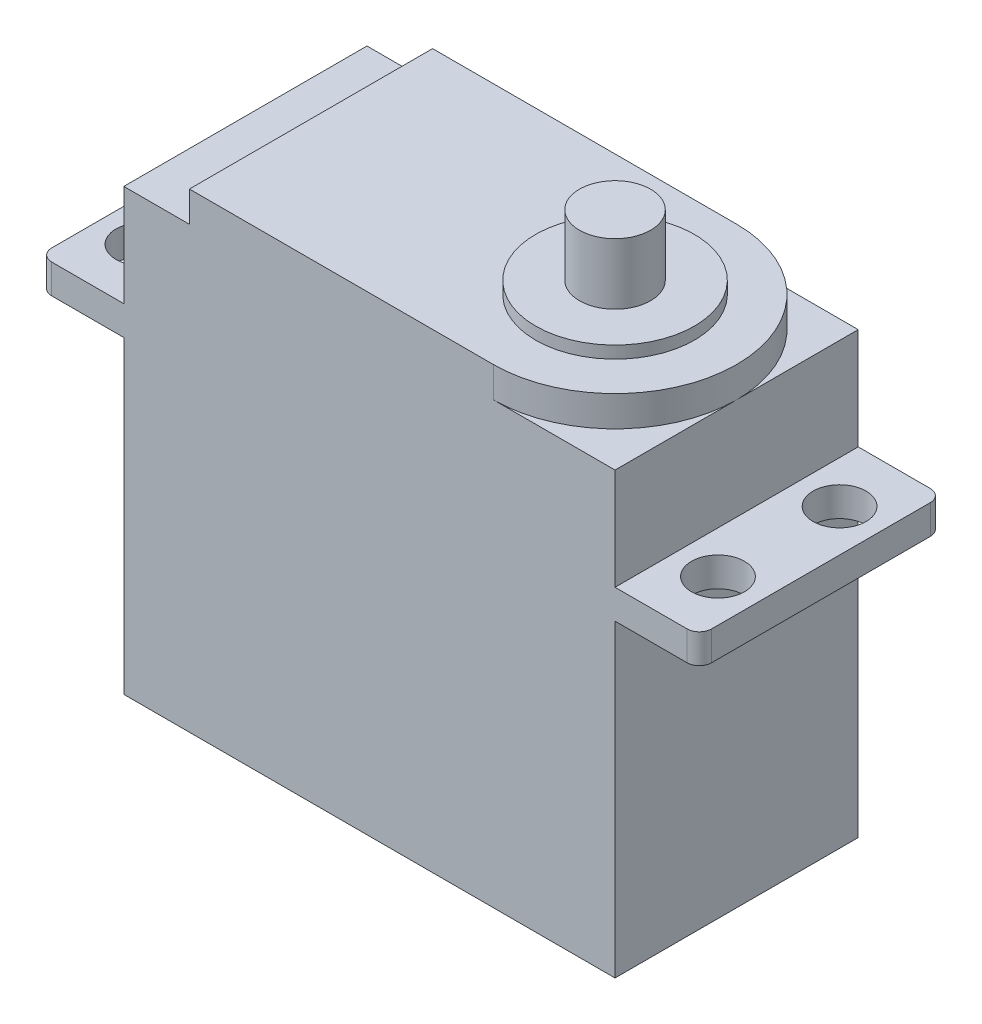
from build123d import *

# Parameters (mm, degrees)
CROQUIS1_W              = 40.2
CROQUIS1_H              = 19.9
SALIENTE_EXTRUIR1_DEPTH = 36
CROQUIS4_W              = 19.9
CROQUIS4_H              = 2.4
SALIENTE_EXTRUIR3_DEPTH = 27
CROQUIS5_R              = 2.165
CORTAR_EXTRUIR2_DEPTH   = 57.31
SALIENTE_EXTRUIR5_DEPTH = 2.5
SALIENTE_EXTRUIR6_DEPTH = 1
CROQUIS8_R              = 2.91
SALIENTE_EXTRUIR7_DEPTH = 5
REDONDEO1_R             = 1


with BuildPart() as part:
    # Croquis1 → Saliente-Extruir1 (new body)
    with BuildSketch(Plane(origin=(0, 0, 0), x_dir=(1, 0, 0), z_dir=(0, 1, 0))):
        Rectangle(CROQUIS1_W, CROQUIS1_H)
    extrude(amount=SALIENTE_EXTRUIR1_DEPTH)

    # Croquis4 → Saliente-Extruir3 (add, symmetric)
    with BuildSketch(Plane(origin=(0, 0, 0), x_dir=(0, 0, -1), z_dir=(1, 0, 0))):
        with Locations((0, 26.49)):
            Rectangle(CROQUIS4_W, CROQUIS4_H)
    extrude(amount=SALIENTE_EXTRUIR3_DEPTH, both=True)

    # Croquis5 → Cortar-Extruir2 (cut)
    with BuildSketch(Plane(origin=(0, 27.69, 0), x_dir=(1, 0, 0), z_dir=(0, 1, 0))):
        with Locations((-23.55, 4.975)):
            Circle(CROQUIS5_R)
        with Locations((-23.55, -4.975)):
            Circle(CROQUIS5_R)
        with Locations((23.55, 4.975)):
            Circle(CROQUIS5_R)
        with Locations((23.55, -4.975)):
            Circle(CROQUIS5_R)
    extrude(amount=-CORTAR_EXTRUIR2_DEPTH, mode=Mode.SUBTRACT)

    # Croquis6 → Saliente-Extruir5 (add)
    with BuildSketch(Plane(origin=(0, 36, 0), x_dir=(1, 0, 0), z_dir=(0, 1, 0))):
        with BuildLine():
            ThreePointArc((10.15, -9.95), (0.2, 0), (10.15, 9.95))
            Line((10.15, 9.95), (-14.73, 9.95))
            Line((-14.73, 9.95), (-14.73, -9.95))
            Line((-14.73, -9.95), (10.15, -9.95))
        make_face()
        with BuildLine():
            ThreePointArc((20.1, 0), (17.185712473, 7.035712473), (10.15, 9.95))
            Line((10.15, 9.95), (10.15, -9.95))
            ThreePointArc((10.15, -9.95), (17.185712473, -7.035712473), (20.1, 0))
        make_face()
        with BuildLine():
            Line((10.15, -9.95), (10.15, 9.95))
            ThreePointArc((10.15, 9.95), (0.2, 0), (10.15, -9.95))
        make_face()
    extrude(amount=SALIENTE_EXTRUIR5_DEPTH)

    # Croquis7 → Saliente-Extruir6 (add)
    with BuildSketch(Plane(origin=(0, 38.5, 0), x_dir=(1, 0, 0), z_dir=(0, 1, 0))):
        with BuildLine():
            ThreePointArc((10.15, 6.5), (3.65, 0), (10.15, -6.5))
            Line((10.15, -6.5), (10.15, 6.5))
        make_face()
        with BuildLine():
            Line((10.15, 6.5), (10.15, -6.5))
            ThreePointArc((10.15, -6.5), (14.746194078, -4.596194078), (16.65, 0))
            ThreePointArc((16.65, 0), (14.746194078, 4.596194078), (10.15, 6.5))
        make_face()
    extrude(amount=SALIENTE_EXTRUIR6_DEPTH)

    # Croquis8 → Saliente-Extruir7 (add)
    with BuildSketch(Plane(origin=(0, 39.5, 0), x_dir=(1, 0, 0), z_dir=(0, 1, 0))):
        with Locations((10.15, 0)):
            Circle(CROQUIS8_R)
    extrude(amount=SALIENTE_EXTRUIR7_DEPTH)

    # Redondeo1
    redondeo1_edges = [part.edges().sort_by_distance(p)[0] for p in [
        (-27, 26.49, -9.95),
        (-27, 26.49, 9.95),
        (27, 26.49, -9.95),
        (27, 26.49, 9.95),
    ]]
    fillet(redondeo1_edges, radius=REDONDEO1_R)


solid = part.part
